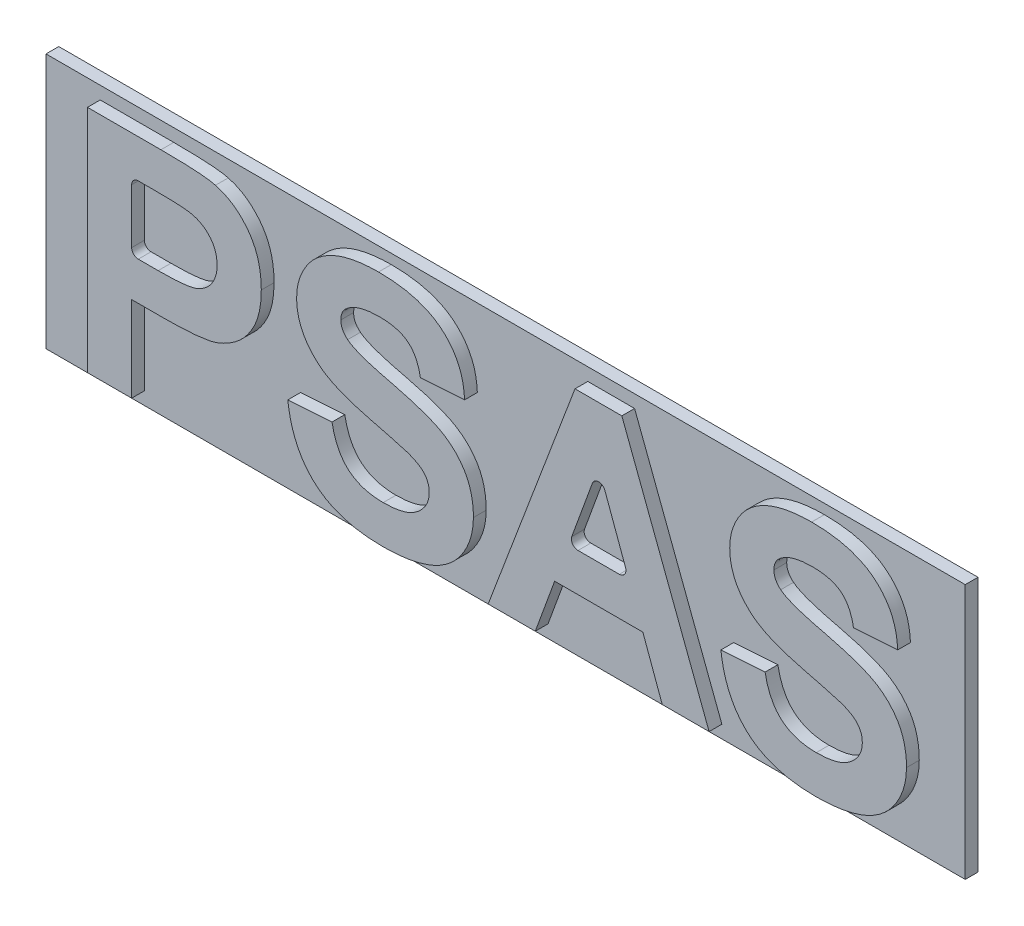
from build123d import *

# Parameters (mm, degrees)
SKETCH1_W           = 228.6
SKETCH1_H           = 63.5
BOSS_EXTRUDE1_DEPTH = 6.35
SKETCH2_OUTSIDE_W   = 278.068
SKETCH2_OUTSIDE_H   = 112.968
CUT_EXTRUDE1_DEPTH  = 3.175
FILLET1_R           = 1.651


with BuildPart() as part:
    # Sketch1 → Boss-Extrude1 (new body)
    with BuildSketch(Plane.XY):
        Rectangle(SKETCH1_W, SKETCH1_H)
    extrude(amount=BOSS_EXTRUDE1_DEPTH)

    # Sketch2 outside → Cut-Extrude1 (cut)
    with BuildSketch(Plane.XY.offset(6.35)):
        Rectangle(SKETCH2_OUTSIDE_W, SKETCH2_OUTSIDE_H)
        with BuildLine():
            Line((-100.818461538, -28.575), (-100.818461538, 28.575))
            Line((-100.818461538, 28.575), (-82.535498798, 28.575))
            add(Edge.make_bspline(
                [(-82.535498798, 28.575), (-81.707376778, 28.574095652), (-80.123494966, 28.572365978), (-77.864183367, 28.524308393), (-75.830011754, 28.456277586), (-74.023999164, 28.371548094), (-72.439790713, 28.245115419), (-71.084492982, 28.098708284), (-69.94957175, 27.941213058), (-69.281250256, 27.778226563), (-68.980691106, 27.704927885)],
                knots=[0, 0, 0, 0, 0.002484311, 0.004751541, 0.006779057, 0.008590208, 0.010175087, 0.011545542, 0.012680543, 0.013608139, 0.013608139, 0.013608139, 0.013608139], degree=3))
            add(Edge.make_bspline(
                [(-68.980691106, 27.704927885), (-68.581020524, 27.5909664), (-67.787768057, 27.364779553), (-66.651284638, 26.882585124), (-65.555894583, 26.323747505), (-64.515360297, 25.657714076), (-63.526144676, 24.896309283), (-62.585307318, 24.04574248), (-61.687830874, 23.102174032), (-60.846130775, 22.067467901), (-60.0752325, 20.946841612), (-59.4089827, 19.738638346), (-58.850804673, 18.448109573), (-58.375246271, 17.084953457), (-58.024377013, 15.634554754), (-57.778832323, 14.106990998), (-57.607902581, 12.501594068), (-57.595800226, 11.402991341), (-57.589615385, 10.84155649)],
                knots=[0, 0, 0, 0, 0.001245712, 0.002472446, 0.003696185, 0.004931595, 0.006172669, 0.007437177, 0.008732811, 0.010075587, 0.011434662, 0.012807935, 0.014207489, 0.015648431, 0.017133936, 0.018677252, 0.020288011, 0.021971536, 0.021971536, 0.021971536, 0.021971536], degree=3))
            add(Edge.make_bspline(
                [(-57.589615385, 10.84155649), (-57.60725452, 9.988953839), (-57.641210825, 8.34764692), (-58.021121627, 5.994634519), (-58.600579058, 3.845309377), (-59.447497962, 1.920373959), (-60.480068043, 0.212274493), (-61.617465246, -1.327569108), (-62.916205704, -2.652744394), (-64.319380202, -3.784637269), (-65.802279193, -4.710931437), (-67.287862536, -5.500584064), (-68.796176003, -6.107694235), (-69.824540767, -6.372217019), (-70.331592548, -6.502644231)],
                knots=[0, 0, 0, 0, 0.00255554, 0.004919556, 0.007130593, 0.009217141, 0.011204075, 0.013109077, 0.014946844, 0.016754446, 0.018504391, 0.020183981, 0.021797544, 0.023366966, 0.023366966, 0.023366966, 0.023366966], degree=3))
            add(Edge.make_bspline(
                [(-70.331592548, -6.502644231), (-70.693501242, -6.57148777), (-71.456361587, -6.716601735), (-72.666212459, -6.861253947), (-73.988645032, -7.021368175), (-75.429098559, -7.125803671), (-76.985830468, -7.223603134), (-78.658236273, -7.269777489), (-80.443925929, -7.325408211), (-81.673003777, -7.326407825), (-82.306532452, -7.326923077)],
                knots=[0, 0, 0, 0, 0.001104866, 0.002328927, 0.003653868, 0.005100892, 0.006660555, 0.008332989, 0.010119513, 0.012019969, 0.012019969, 0.012019969, 0.012019969], degree=3))
            Line((-82.306532452, -7.326923077), (-89.828076923, -7.326923077))
            Line((-89.828076923, -7.326923077), (-89.828076923, -28.575))
            Line((-89.828076923, -28.575), (-100.818461538, -28.575))
        make_face(mode=Mode.SUBTRACT)
        with BuildLine():
            Line((-50.995384615, -9.525), (-40.005, -8.792307692))
            add(Edge.make_bspline(
                [(-40.005, -8.792307692), (-39.917442717, -9.252106682), (-39.747368264, -10.145236974), (-39.369494765, -11.418069574), (-38.953560622, -12.604710551), (-38.456496527, -13.692435166), (-37.91233831, -14.701349395), (-37.276383164, -15.60271171), (-36.592996933, -16.425300311), (-35.828350686, -17.139571328), (-34.995278523, -17.765139752), (-34.089623498, -18.298645343), (-33.121199159, -18.76040407), (-32.087637602, -19.140647743), (-30.978286388, -19.424501499), (-29.802809591, -19.626446619), (-28.559521364, -19.755766694), (-27.70983287, -19.773570188), (-27.274471154, -19.782692308)],
                knots=[0, 0, 0, 0, 0.001403295, 0.002725811, 0.003978761, 0.005172574, 0.006310113, 0.007412129, 0.00847633, 0.009513019, 0.010543367, 0.011595741, 0.012660865, 0.013758293, 0.014893987, 0.016091034, 0.017333849, 0.01863976, 0.01863976, 0.01863976, 0.01863976], degree=3))
            add(Edge.make_bspline(
                [(-27.274471154, -19.782692308), (-26.816225409, -19.777692875), (-25.92491383, -19.767968722), (-24.633304802, -19.647332057), (-23.425591696, -19.474507053), (-22.312439036, -19.200929124), (-21.273059763, -18.894975499), (-20.333267734, -18.476398348), (-19.477854881, -17.993630115), (-18.70902494, -17.445813252), (-18.038066329, -16.838245045), (-17.451078252, -16.203963549), (-16.939850415, -15.556672147), (-16.537477925, -14.86764688), (-16.211843266, -14.164754784), (-15.996621558, -13.427027372), (-15.851226553, -12.67140446), (-15.834553981, -12.154987703), (-15.826153846, -11.894801683)],
                knots=[0, 0, 0, 0, 0.001374227, 0.002672943, 0.003888892, 0.005030169, 0.00610923, 0.007134478, 0.008108595, 0.009052161, 0.009960122, 0.010818822, 0.01164318, 0.012428538, 0.01320736, 0.013960691, 0.014728667, 0.015508499, 0.015508499, 0.015508499, 0.015508499], degree=3))
            add(Edge.make_bspline(
                [(-15.826153846, -11.894801683), (-15.836455896, -11.568809704), (-15.856610349, -10.931054104), (-16.099249776, -10.019312614), (-16.463126666, -9.174610468), (-17.010999524, -8.409423921), (-17.747475494, -7.71015494), (-18.68692399, -7.05600592), (-19.855568247, -6.467527645), (-20.722550271, -6.139273365), (-21.183966346, -5.964573317)],
                knots=[0, 0, 0, 0, 0.000975528, 0.001908478, 0.002810501, 0.003722135, 0.00470988, 0.005843784, 0.007144315, 0.008623941, 0.008623941, 0.008623941, 0.008623941], degree=3))
            add(Edge.make_bspline(
                [(-21.183966346, -5.964573317), (-21.381947767, -5.89822883), (-21.824998032, -5.749760642), (-22.580794742, -5.537465134), (-23.491171964, -5.272364447), (-24.569285212, -4.9710352), (-25.814771979, -4.662854702), (-27.213721813, -4.283211296), (-28.783189458, -3.905435077), (-29.881190911, -3.626560758), (-30.457103365, -3.480288462)],
                knots=[0, 0, 0, 0, 0.000626318, 0.001401598, 0.002354563, 0.003471112, 0.004759493, 0.006203434, 0.007819432, 0.009602027, 0.009602027, 0.009602027, 0.009602027], degree=3))
            add(Edge.make_bspline(
                [(-30.457103365, -3.480288462), (-31.207112307, -3.293028732), (-32.654131915, -2.931741706), (-34.717913229, -2.289037686), (-36.618693564, -1.650475659), (-38.338171482, -0.957601594), (-39.895313538, -0.257373428), (-41.264932491, 0.499369493), (-42.475609284, 1.273326818), (-43.181098752, 1.851801433), (-43.519633413, 2.129387019)],
                knots=[0, 0, 0, 0, 0.002318588, 0.004473337, 0.006482671, 0.008332203, 0.010032924, 0.0116008, 0.013023343, 0.014335712, 0.014335712, 0.014335712, 0.014335712], degree=3))
            add(Edge.make_bspline(
                [(-43.519633413, 2.129387019), (-43.939460399, 2.52246922), (-44.762570025, 3.293143222), (-45.846066096, 4.559508519), (-46.756497829, 5.897220839), (-47.505882818, 7.296406082), (-48.082895086, 8.765119296), (-48.491873961, 10.293529528), (-48.756579949, 11.885625762), (-48.78359137, 12.969881015), (-48.797307692, 13.52046274)],
                knots=[0, 0, 0, 0, 0.001724445, 0.003380934, 0.004987659, 0.006570221, 0.00813278, 0.009710199, 0.011310016, 0.012960521, 0.012960521, 0.012960521, 0.012960521], degree=3))
            add(Edge.make_bspline(
                [(-48.797307692, 13.52046274), (-48.770595043, 14.232908925), (-48.717605122, 15.646189488), (-48.231653011, 17.723518996), (-47.474672402, 19.727981977), (-46.596754393, 21.31959981), (-45.753264603, 22.523664723), (-45.052807734, 23.387690682), (-44.283288193, 24.196335921), (-43.434165193, 24.929875018), (-42.536968776, 25.631275561), (-41.556938093, 26.254127643), (-40.52185999, 26.840819846), (-39.023984045, 27.536316158), (-36.990279527, 28.26109163), (-34.344320688, 28.872031355), (-31.463395461, 29.23928504), (-29.466041132, 29.284339303), (-28.430751202, 29.307692308)],
                knots=[0, 0, 0, 0, 0.002134582, 0.004234373, 0.006364867, 0.008547657, 0.009665613, 0.010772376, 0.011881681, 0.013009268, 0.014135866, 0.01529492, 0.016489172, 0.017702964, 0.020245057, 0.022949769, 0.0258352, 0.028940248, 0.028940248, 0.028940248, 0.028940248], degree=3))
            add(Edge.make_bspline(
                [(-28.430751202, 29.307692308), (-27.58305493, 29.296356482), (-25.934303807, 29.274308543), (-23.544247535, 29.051356303), (-21.311805302, 28.704357501), (-19.244811004, 28.206242341), (-17.342301571, 27.548101471), (-15.596902324, 26.764131258), (-14.01009642, 25.83336189), (-12.601201659, 24.750452022), (-11.346011469, 23.556613344), (-10.251058769, 22.252595022), (-9.312157333, 20.854866002), (-8.523247612, 19.364447741), (-7.903718886, 17.77367731), (-7.448699495, 16.084539671), (-7.147745723, 14.301010642), (-7.072310747, 13.078918734), (-7.033846154, 12.455769231)],
                knots=[0, 0, 0, 0, 0.002542455, 0.00494502, 0.00719417, 0.00931554, 0.01131405, 0.013225097, 0.015047142, 0.016819414, 0.018544163, 0.020234254, 0.021917118, 0.023586572, 0.025283087, 0.027027181, 0.028826462, 0.030698463, 0.030698463, 0.030698463, 0.030698463], degree=3))
            Line((-7.033846154, 12.455769231), (-18.024230769, 11.723076923))
            add(Edge.make_bspline(
                [(-18.024230769, 11.723076923), (-18.087631522, 12.067705909), (-18.211192996, 12.739351959), (-18.479849481, 13.701285564), (-18.782880958, 14.590964428), (-19.137563602, 15.408382845), (-19.565977379, 16.138900082), (-20.032214691, 16.805498589), (-20.549136886, 17.399296317), (-21.133859472, 17.904033175), (-21.76628887, 18.363323032), (-22.487035493, 18.731454481), (-23.265899273, 19.072999435), (-24.132511245, 19.329757486), (-25.070229316, 19.533427197), (-26.079599694, 19.684414685), (-27.162714669, 19.758135272), (-27.907857853, 19.774319236), (-28.293371394, 19.782692308)],
                knots=[0, 0, 0, 0, 0.001050753, 0.002047809, 0.002992764, 0.003869214, 0.004715539, 0.005528692, 0.006307345, 0.007069841, 0.007841733, 0.008645809, 0.009492133, 0.010390224, 0.011351338, 0.012369723, 0.013448845, 0.014605635, 0.014605635, 0.014605635, 0.014605635], degree=3))
            add(Edge.make_bspline(
                [(-28.293371394, 19.782692308), (-28.694200196, 19.775300263), (-29.474030537, 19.76091871), (-30.610451194, 19.672661233), (-31.676499037, 19.509746427), (-32.677409722, 19.297671766), (-33.611846274, 19.009158854), (-34.47783674, 18.657364619), (-35.279343099, 18.243194507), (-35.768066728, 17.917339763), (-36.00953726, 17.756340144)],
                knots=[0, 0, 0, 0, 0.001202564, 0.002339642, 0.003416331, 0.00443581, 0.005406287, 0.006345956, 0.007236942, 0.008107089, 0.008107089, 0.008107089, 0.008107089], degree=3))
            add(Edge.make_bspline(
                [(-36.00953726, 17.756340144), (-36.285880008, 17.536410089), (-36.821070136, 17.110473838), (-37.397047964, 16.264709265), (-37.743787947, 15.309443537), (-37.785522036, 14.633910233), (-37.806923077, 14.2875)],
                knots=[0, 0, 0, 0, 0.001054365, 0.002041977, 0.003026931, 0.004063621, 0.004063621, 0.004063621, 0.004063621], degree=3))
            add(Edge.make_bspline(
                [(-37.806923077, 14.2875), (-37.789420927, 13.963756638), (-37.754944477, 13.326033736), (-37.40720508, 12.42013455), (-36.87242926, 11.580753794), (-36.372768972, 11.124791168), (-36.112572115, 10.88734976)],
                knots=[0, 0, 0, 0, 0.000967163, 0.001905156, 0.002873673, 0.003926047, 0.003926047, 0.003926047, 0.003926047], degree=3))
            add(Edge.make_bspline(
                [(-36.112572115, 10.88734976), (-35.906072383, 10.733238374), (-35.444631432, 10.388863571), (-34.599363076, 9.951130619), (-33.579101988, 9.477039388), (-32.36058868, 9.013562864), (-30.951921366, 8.550946675), (-29.353014377, 8.067921895), (-27.562884318, 7.578412052), (-25.627160723, 7.104345747), (-23.661856085, 6.638365801), (-21.786420021, 6.128918201), (-20.04253418, 5.63224619), (-18.438284462, 5.111653325), (-16.965401256, 4.604857784), (-15.63103931, 4.084342265), (-14.426036374, 3.577418392), (-13.020869364, 2.880362158), (-11.428253885, 1.936171319), (-9.759013204, 0.563632467), (-8.282782826, -0.979190843), (-7.254184733, -2.433966802), (-6.547591666, -3.685112839), (-6.092620285, -4.682421914), (-5.699034351, -5.733334206), (-5.378656475, -6.839011052), (-5.146459602, -8.001008273), (-4.954303178, -9.210448197), (-4.856126898, -10.477375494), (-4.842628155, -11.341329759), (-4.835769231, -11.78031851)],
                knots=[0, 0, 0, 0, 0.000771892, 0.001724857, 0.002846675, 0.00414781, 0.005632123, 0.007294496, 0.009158077, 0.011198898, 0.013273067, 0.01521699, 0.017028575, 0.018712101, 0.020276211, 0.021700641, 0.023008458, 0.024196272, 0.026405085, 0.028545309, 0.030658911, 0.032793585, 0.03386997, 0.034966203, 0.03607834, 0.037234167, 0.038415176, 0.039631125, 0.040906059, 0.042223063, 0.042223063, 0.042223063, 0.042223063], degree=3))
            add(Edge.make_bspline(
                [(-4.835769231, -11.78031851), (-4.845200471, -12.185164283), (-4.86393, -12.989148771), (-4.994817026, -14.182464717), (-5.197230532, -15.354589576), (-5.496872062, -16.506992755), (-5.894377127, -17.637407229), (-6.341936248, -18.762148005), (-6.901583724, -19.856686854), (-7.538538885, -20.921930316), (-8.241129365, -21.957079002), (-9.037294881, -22.911980091), (-9.880271783, -23.818491375), (-10.823924042, -24.625853287), (-11.809979022, -25.399438368), (-12.883537855, -26.084538314), (-14.019448623, -26.704493115), (-15.224893491, -27.25467417), (-16.504146432, -27.734107231), (-17.855545952, -28.160835988), (-19.291267356, -28.510080699), (-20.799338772, -28.809427412), (-22.385279068, -29.037072853), (-24.047105474, -29.196022303), (-25.785195774, -29.285660212), (-26.96908281, -29.300257028), (-27.572127404, -29.307692308)],
                knots=[0, 0, 0, 0, 0.001214385, 0.002411652, 0.003597423, 0.004780318, 0.005978678, 0.00719047, 0.008409004, 0.00966164, 0.010912811, 0.012157312, 0.013388206, 0.014621334, 0.015878461, 0.017145506, 0.018436529, 0.019758252, 0.021116941, 0.022532696, 0.024007086, 0.025547299, 0.027143673, 0.028811398, 0.030553951, 0.032363111, 0.032363111, 0.032363111, 0.032363111], degree=3))
            add(Edge.make_bspline(
                [(-27.572127404, -29.307692308), (-28.442830751, -29.293476595), (-30.138110819, -29.265798266), (-32.601048285, -29.018055436), (-34.911120582, -28.638867168), (-37.064567084, -28.088537079), (-39.064019831, -27.382037464), (-40.908566887, -26.511785944), (-42.589286399, -25.472583223), (-44.126994967, -24.289631715), (-45.501205044, -22.941375059), (-46.736897516, -21.455748629), (-47.817402538, -19.819374616), (-48.742009906, -18.034812511), (-49.534095286, -16.111709644), (-50.187335725, -14.049182951), (-50.679191443, -11.837395291), (-50.888164039, -10.309129381), (-50.995384615, -9.525)],
                knots=[0, 0, 0, 0, 0.002611446, 0.005084548, 0.007418348, 0.009628585, 0.011743273, 0.013771144, 0.015734656, 0.017660493, 0.019579205, 0.021497951, 0.023447529, 0.025449709, 0.027518341, 0.029679891, 0.031932418, 0.034306005, 0.034306005, 0.034306005, 0.034306005], degree=3))
        make_face(mode=Mode.SUBTRACT)
        Polygon((53.779615385, -28.575), (42.125228365, -28.575), (37.305486779, -15.386538462), (15.370510817, -15.386538462), (10.550769231, -28.575), (-1.172307692, -28.575), (20.430667067, 28.575), (32.073605769, 28.575), align=None, mode=Mode.SUBTRACT)
        with BuildLine():
            Line((56.710384615, -9.525), (67.700769231, -8.792307692))
            add(Edge.make_bspline(
                [(67.700769231, -8.792307692), (67.788326514, -9.252106682), (67.958400966, -10.145236974), (68.336274466, -11.418069574), (68.752208608, -12.604710551), (69.249272704, -13.692435166), (69.79343092, -14.701349395), (70.429386066, -15.60271171), (71.112772298, -16.425300311), (71.877418545, -17.139571328), (72.710490708, -17.765139752), (73.616145732, -18.298645343), (74.584570071, -18.76040407), (75.618131629, -19.140647743), (76.727482843, -19.424501499), (77.902959639, -19.626446619), (79.146247866, -19.755766694), (79.995936361, -19.773570188), (80.431298077, -19.782692308)],
                knots=[0, 0, 0, 0, 0.001403295, 0.002725811, 0.003978761, 0.005172574, 0.006310113, 0.007412129, 0.00847633, 0.009513019, 0.010543367, 0.011595741, 0.012660865, 0.013758293, 0.014893987, 0.016091034, 0.017333849, 0.01863976, 0.01863976, 0.01863976, 0.01863976], degree=3))
            add(Edge.make_bspline(
                [(80.431298077, -19.782692308), (80.889543822, -19.777692875), (81.7808554, -19.767968722), (83.072464429, -19.647332057), (84.280177535, -19.474507053), (85.393330195, -19.200929124), (86.432709468, -18.894975499), (87.372501497, -18.476398348), (88.22791435, -17.993630115), (88.99674429, -17.445813252), (89.667702902, -16.838245045), (90.254690978, -16.203963549), (90.765918816, -15.556672147), (91.168291305, -14.86764688), (91.493925965, -14.164754784), (91.709147673, -13.427027372), (91.854542678, -12.67140446), (91.87121525, -12.154987703), (91.879615385, -11.894801683)],
                knots=[0, 0, 0, 0, 0.001374227, 0.002672943, 0.003888892, 0.005030169, 0.00610923, 0.007134478, 0.008108595, 0.009052161, 0.009960122, 0.010818822, 0.01164318, 0.012428538, 0.01320736, 0.013960691, 0.014728667, 0.015508499, 0.015508499, 0.015508499, 0.015508499], degree=3))
            add(Edge.make_bspline(
                [(91.879615385, -11.894801683), (91.869313335, -11.568809704), (91.849158881, -10.931054104), (91.606519454, -10.019312614), (91.242642565, -9.174610468), (90.694769707, -8.409423921), (89.958293736, -7.71015494), (89.018845241, -7.05600592), (87.850200984, -6.467527645), (86.98321896, -6.139273365), (86.521802885, -5.964573317)],
                knots=[0, 0, 0, 0, 0.000975528, 0.001908478, 0.002810501, 0.003722135, 0.00470988, 0.005843784, 0.007144315, 0.008623941, 0.008623941, 0.008623941, 0.008623941], degree=3))
            add(Edge.make_bspline(
                [(86.521802885, -5.964573317), (86.323821464, -5.89822883), (85.880771199, -5.749760642), (85.124974489, -5.537465134), (84.214597267, -5.272364447), (83.136484019, -4.9710352), (81.890997251, -4.662854702), (80.492047418, -4.283211296), (78.922579773, -3.905435077), (77.82457832, -3.626560758), (77.248665865, -3.480288462)],
                knots=[0, 0, 0, 0, 0.000626318, 0.001401598, 0.002354563, 0.003471112, 0.004759493, 0.006203434, 0.007819432, 0.009602027, 0.009602027, 0.009602027, 0.009602027], degree=3))
            add(Edge.make_bspline(
                [(77.248665865, -3.480288462), (76.498656924, -3.293028732), (75.051637316, -2.931741706), (72.987856001, -2.289037686), (71.087075667, -1.650475659), (69.367597749, -0.957601594), (67.810455693, -0.257373428), (66.44083674, 0.499369493), (65.230159946, 1.273326818), (64.524670478, 1.851801433), (64.186135817, 2.129387019)],
                knots=[0, 0, 0, 0, 0.002318588, 0.004473337, 0.006482671, 0.008332203, 0.010032924, 0.0116008, 0.013023343, 0.014335712, 0.014335712, 0.014335712, 0.014335712], degree=3))
            add(Edge.make_bspline(
                [(64.186135817, 2.129387019), (63.766308832, 2.52246922), (62.943199206, 3.293143222), (61.859703135, 4.559508519), (60.949271402, 5.897220839), (60.199886413, 7.296406082), (59.622874144, 8.765119296), (59.21389527, 10.293529528), (58.949189282, 11.885625762), (58.922177861, 12.969881015), (58.908461538, 13.52046274)],
                knots=[0, 0, 0, 0, 0.001724445, 0.003380934, 0.004987659, 0.006570221, 0.00813278, 0.009710199, 0.011310016, 0.012960521, 0.012960521, 0.012960521, 0.012960521], degree=3))
            add(Edge.make_bspline(
                [(58.908461538, 13.52046274), (58.935174187, 14.232908925), (58.988164109, 15.646189488), (59.47411622, 17.723518996), (60.231096829, 19.727981977), (61.109014838, 21.31959981), (61.952504628, 22.523664723), (62.652961496, 23.387690682), (63.422481037, 24.196335921), (64.271604038, 24.929875018), (65.168800455, 25.631275561), (66.148831138, 26.254127643), (67.183909241, 26.840819846), (68.681785185, 27.536316158), (70.715489704, 28.26109163), (73.361448543, 28.872031355), (76.24237377, 29.23928504), (78.239728099, 29.284339303), (79.275018029, 29.307692308)],
                knots=[0, 0, 0, 0, 0.002134582, 0.004234373, 0.006364867, 0.008547657, 0.009665613, 0.010772376, 0.011881681, 0.013009268, 0.014135866, 0.01529492, 0.016489172, 0.017702964, 0.020245057, 0.022949769, 0.0258352, 0.028940248, 0.028940248, 0.028940248, 0.028940248], degree=3))
            add(Edge.make_bspline(
                [(79.275018029, 29.307692308), (80.1227143, 29.296356482), (81.771465424, 29.274308543), (84.161521695, 29.051356303), (86.393963929, 28.704357501), (88.460958227, 28.206242341), (90.363467659, 27.548101471), (92.108866907, 26.764131258), (93.695672811, 25.83336189), (95.104567572, 24.750452022), (96.359757762, 23.556613344), (97.454710462, 22.252595022), (98.393611898, 20.854866002), (99.182521619, 19.364447741), (99.802050345, 17.77367731), (100.257069736, 16.084539671), (100.558023507, 14.301010642), (100.633458484, 13.078918734), (100.671923077, 12.455769231)],
                knots=[0, 0, 0, 0, 0.002542455, 0.00494502, 0.00719417, 0.00931554, 0.01131405, 0.013225097, 0.015047142, 0.016819414, 0.018544163, 0.020234254, 0.021917118, 0.023586572, 0.025283087, 0.027027181, 0.028826462, 0.030698463, 0.030698463, 0.030698463, 0.030698463], degree=3))
            Line((100.671923077, 12.455769231), (89.681538462, 11.723076923))
            add(Edge.make_bspline(
                [(89.681538462, 11.723076923), (89.618137709, 12.067705909), (89.494576235, 12.739351959), (89.22591975, 13.701285564), (88.922888272, 14.590964428), (88.568205628, 15.408382845), (88.139791852, 16.138900082), (87.67355454, 16.805498589), (87.156632344, 17.399296317), (86.571909759, 17.904033175), (85.939480361, 18.363323032), (85.218733738, 18.731454481), (84.439869958, 19.072999435), (83.573257986, 19.329757486), (82.635539915, 19.533427197), (81.626169537, 19.684414685), (80.543054561, 19.758135272), (79.797911377, 19.774319236), (79.412397837, 19.782692308)],
                knots=[0, 0, 0, 0, 0.001050753, 0.002047809, 0.002992764, 0.003869214, 0.004715539, 0.005528692, 0.006307345, 0.007069841, 0.007841733, 0.008645809, 0.009492133, 0.010390224, 0.011351338, 0.012369723, 0.013448845, 0.014605635, 0.014605635, 0.014605635, 0.014605635], degree=3))
            add(Edge.make_bspline(
                [(79.412397837, 19.782692308), (79.011569035, 19.775300263), (78.231738693, 19.76091871), (77.095318036, 19.672661233), (76.029270194, 19.509746427), (75.028359509, 19.297671766), (74.093922957, 19.009158854), (73.227932491, 18.657364619), (72.426426131, 18.243194507), (71.937702503, 17.917339763), (71.696231971, 17.756340144)],
                knots=[0, 0, 0, 0, 0.001202564, 0.002339642, 0.003416331, 0.00443581, 0.005406287, 0.006345956, 0.007236942, 0.008107089, 0.008107089, 0.008107089, 0.008107089], degree=3))
            add(Edge.make_bspline(
                [(71.696231971, 17.756340144), (71.419889223, 17.536410089), (70.884699095, 17.110473838), (70.308721267, 16.264709265), (69.961981284, 15.309443537), (69.920247194, 14.633910233), (69.898846154, 14.2875)],
                knots=[0, 0, 0, 0, 0.001054365, 0.002041977, 0.003026931, 0.004063621, 0.004063621, 0.004063621, 0.004063621], degree=3))
            add(Edge.make_bspline(
                [(69.898846154, 14.2875), (69.916348304, 13.963756638), (69.950824754, 13.326033736), (70.298564151, 12.42013455), (70.833339971, 11.580753794), (71.333000258, 11.124791168), (71.593197115, 10.88734976)],
                knots=[0, 0, 0, 0, 0.000967163, 0.001905156, 0.002873673, 0.003926047, 0.003926047, 0.003926047, 0.003926047], degree=3))
            add(Edge.make_bspline(
                [(71.593197115, 10.88734976), (71.799696848, 10.733238374), (72.261137799, 10.388863571), (73.106406155, 9.951130619), (74.126667243, 9.477039388), (75.345180551, 9.013562864), (76.753847864, 8.550946675), (78.352754854, 8.067921895), (80.142884912, 7.578412052), (82.078608508, 7.104345747), (84.043913146, 6.638365801), (85.91934921, 6.128918201), (87.663235051, 5.63224619), (89.267484769, 5.111653325), (90.740367975, 4.604857784), (92.074729921, 4.084342265), (93.279732857, 3.577418392), (94.684899867, 2.880362158), (96.277515346, 1.936171319), (97.946756027, 0.563632467), (99.422986405, -0.979190843), (100.451584498, -2.433966802), (101.158177565, -3.685112839), (101.613148946, -4.682421914), (102.00673488, -5.733334206), (102.327112756, -6.839011052), (102.559309629, -8.001008273), (102.751466053, -9.210448197), (102.849642333, -10.477375494), (102.863141076, -11.341329759), (102.87, -11.78031851)],
                knots=[0, 0, 0, 0, 0.000771892, 0.001724857, 0.002846675, 0.00414781, 0.005632123, 0.007294496, 0.009158077, 0.011198898, 0.013273067, 0.01521699, 0.017028575, 0.018712101, 0.020276211, 0.021700641, 0.023008458, 0.024196272, 0.026405085, 0.028545309, 0.030658911, 0.032793585, 0.03386997, 0.034966203, 0.03607834, 0.037234167, 0.038415176, 0.039631125, 0.040906059, 0.042223063, 0.042223063, 0.042223063, 0.042223063], degree=3))
            add(Edge.make_bspline(
                [(102.87, -11.78031851), (102.86056876, -12.185164283), (102.841839231, -12.989148771), (102.710952204, -14.182464717), (102.508538699, -15.354589576), (102.208897168, -16.506992755), (101.811392103, -17.637407229), (101.363832983, -18.762148005), (100.804185506, -19.856686854), (100.167230346, -20.921930316), (99.464639866, -21.957079002), (98.668474349, -22.911980091), (97.825497448, -23.818491375), (96.881845189, -24.625853287), (95.895790208, -25.399438368), (94.822231376, -26.084538314), (93.686320608, -26.704493115), (92.48087574, -27.25467417), (91.201622799, -27.734107231), (89.850223279, -28.160835988), (88.414501875, -28.510080699), (86.906430459, -28.809427412), (85.320490163, -29.037072853), (83.658663757, -29.196022303), (81.920573457, -29.285660212), (80.736686421, -29.300257028), (80.133641827, -29.307692308)],
                knots=[0, 0, 0, 0, 0.001214385, 0.002411652, 0.003597423, 0.004780318, 0.005978678, 0.00719047, 0.008409004, 0.00966164, 0.010912811, 0.012157312, 0.013388206, 0.014621334, 0.015878461, 0.017145506, 0.018436529, 0.019758252, 0.021116941, 0.022532696, 0.024007086, 0.025547299, 0.027143673, 0.028811398, 0.030553951, 0.032363111, 0.032363111, 0.032363111, 0.032363111], degree=3))
            add(Edge.make_bspline(
                [(80.133641827, -29.307692308), (79.262938479, -29.293476595), (77.567658412, -29.265798266), (75.104720946, -29.018055436), (72.794648649, -28.638867168), (70.641202147, -28.088537079), (68.6417494, -27.382037464), (66.797202344, -26.511785944), (65.116482831, -25.472583223), (63.578774264, -24.289631715), (62.204564187, -22.941375059), (60.968871715, -21.455748629), (59.888366693, -19.819374616), (58.963759325, -18.034812511), (58.171673945, -16.111709644), (57.518433505, -14.049182951), (57.026577788, -11.837395291), (56.817605192, -10.309129381), (56.710384615, -9.525)],
                knots=[0, 0, 0, 0, 0.002611446, 0.005084548, 0.007418348, 0.009628585, 0.011743273, 0.013771144, 0.015734656, 0.017660493, 0.019579205, 0.021497951, 0.023447529, 0.025449709, 0.027518341, 0.029679891, 0.031932418, 0.034306005, 0.034306005, 0.034306005, 0.034306005], degree=3))
        make_face(mode=Mode.SUBTRACT)
        with BuildLine():
            Line((-89.828076923, 19.05), (-89.828076923, 2.198076923))
            Line((-89.828076923, 2.198076923), (-83.233846154, 2.198076923))
            add(Edge.make_bspline(
                [(-83.233846154, 2.198076923), (-82.665196452, 2.198813276), (-81.577298026, 2.200222013), (-80.01640511, 2.250787396), (-78.603483363, 2.312511822), (-77.335580534, 2.414678378), (-76.220350021, 2.549331455), (-75.250323398, 2.710393495), (-74.424370122, 2.883229891), (-73.531214097, 3.169647496), (-72.576251735, 3.633045064), (-71.556464161, 4.299063762), (-70.660581981, 5.095367665), (-69.915089262, 6.030599024), (-69.319605632, 7.069695249), (-68.893238919, 8.202007339), (-68.617934333, 9.408768922), (-68.592787769, 10.244723951), (-68.58, 10.669831731)],
                knots=[0, 0, 0, 0, 0.001705838, 0.003263482, 0.004684734, 0.005948257, 0.007078572, 0.008053496, 0.008897882, 0.009607493, 0.010862116, 0.012068705, 0.013252375, 0.014441348, 0.015641238, 0.01682977, 0.018060344, 0.019333632, 0.019333632, 0.019333632, 0.019333632], degree=3))
            add(Edge.make_bspline(
                [(-68.58, 10.669831731), (-68.597997383, 11.187606369), (-68.632891934, 12.191503121), (-69.017681433, 13.621219641), (-69.61136766, 14.918704714), (-70.460170413, 16.043587726), (-71.48550416, 16.989521833), (-72.637936501, 17.776572641), (-73.942078148, 18.327356788), (-74.865060876, 18.540765313), (-75.334507212, 18.649308894)],
                knots=[0, 0, 0, 0, 0.001549757, 0.003004775, 0.00440807, 0.005807061, 0.00720028, 0.008578317, 0.009973321, 0.011417262, 0.011417262, 0.011417262, 0.011417262], degree=3))
            add(Edge.make_bspline(
                [(-75.334507212, 18.649308894), (-75.536520695, 18.681619304), (-75.984927995, 18.753338395), (-76.730272183, 18.828186187), (-77.612014475, 18.896260178), (-78.631217725, 18.952150958), (-79.783842066, 18.995844606), (-81.073689372, 19.034131019), (-82.497362585, 19.037206823), (-83.493350669, 19.045617458), (-84.012331731, 19.05)],
                knots=[0, 0, 0, 0, 0.000613634, 0.001362077, 0.00224627, 0.003266777, 0.004423963, 0.005706635, 0.00713772, 0.008694734, 0.008694734, 0.008694734, 0.008694734], degree=3))
            Line((-84.012331731, 19.05), (-89.828076923, 19.05))
        make_face()
        Polygon((33.81375, -5.861538462), (26.303653846, 14.653846154), (18.816454327, -5.861538462), align=None)
    extrude(amount=-CUT_EXTRUDE1_DEPTH, mode=Mode.SUBTRACT)

    # Fillet1
    fillet1_edges = [part.edges().sort_by_distance(p)[0] for p in [
        (-89.828076923, 19.05, 4.7625),
        (-89.828076923, 2.198076923, 4.7625),
        (33.81375, -5.861538462, 4.7625),
        (18.816454327, -5.861538462, 4.7625),
        (26.303653846, 14.653846154, 4.7625),
    ]]
    fillet(fillet1_edges, radius=FILLET1_R)


solid = part.part
